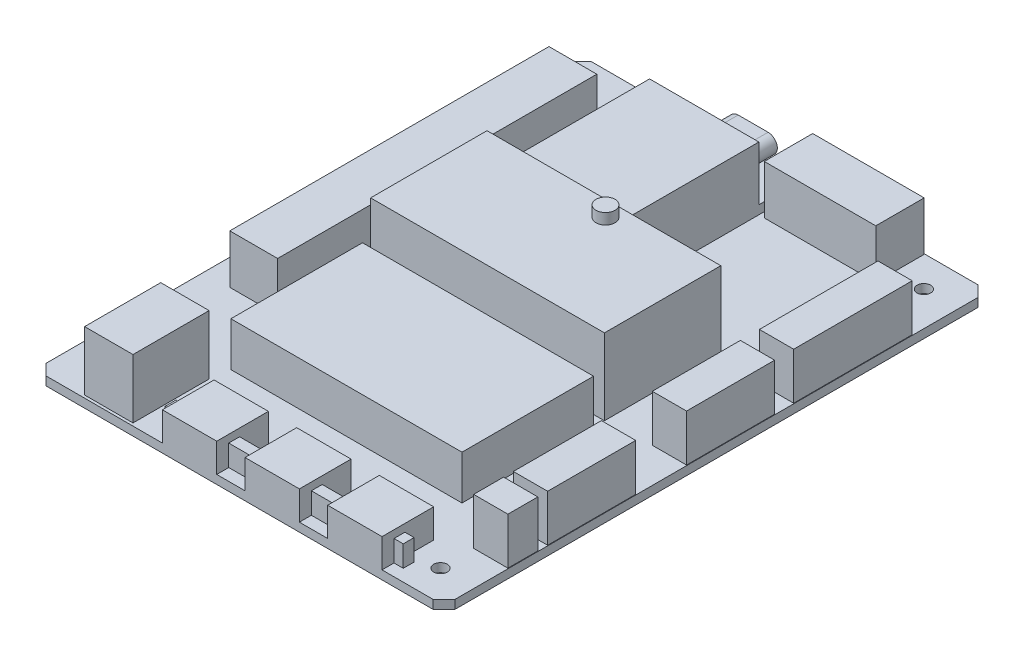
from build123d import *

# Parameters (mm, degrees)
SKETCH1_W            = 75.2
SKETCH1_H            = 100.2
BOSS_EXTRUDE1_DEPTH  = 1.6
CHAMFER1_SIZE        = 2
SKETCH2_R            = 1.25
CUT_EXTRUDE1_DEPTH   = 63.660434087
SKETCH3_W            = 8.8
SKETCH3_H            = 58.7
SKETCH3_W_2          = 20.5
SKETCH3_H_2          = 8.9
BOSS_EXTRUDE2_DEPTH  = 9
SKETCH3_3_W          = 20.1
SKETCH3_3_H          = 32
BOSS_EXTRUDE3_DEPTH  = 1.6
SKETCH3_4_W          = 6.3
SKETCH3_4_H          = 21.8
SKETCH3_4_H_2        = 16.2
SKETCH3_4_H_3        = 5.5
BOSS_EXTRUDE4_DEPTH  = 8.6
SKETCH3_5_W          = 10
SKETCH3_5_H          = 9.5
BOSS_EXTRUDE5_DEPTH  = 5.3
SKETCH3_6_W          = 8.9
SKETCH3_6_H          = 14
BOSS_EXTRUDE6_DEPTH  = 10.9
BOSS_EXTRUDE7_DEPTH  = 8
SKETCH5_W            = 43.8
SKETCH5_H            = 2
BOSS_EXTRUDE8_DEPTH  = 3.9
SKETCH7_W            = 42.5
SKETCH7_H            = 24.2
BOSS_EXTRUDE9_DEPTH  = 8.1
SKETCH7_3_W          = 43
SKETCH7_3_H          = 21.4
BOSS_EXTRUDE10_DEPTH = 14
SKETCH8_W            = 20.1
SKETCH8_H            = 24
BOSS_EXTRUDE11_DEPTH = 10
SKETCH9_R            = 1.75
BOSS_EXTRUDE12_DEPTH = 2


with BuildPart() as part:
    # Sketch1 → Boss-Extrude1 (new body)
    with BuildSketch(Plane(origin=(0, 0, 0), x_dir=(1, 0, 0), z_dir=(0, 1, 0))):
        Rectangle(SKETCH1_W, SKETCH1_H)
    extrude(amount=BOSS_EXTRUDE1_DEPTH)

    # Chamfer1
    chamfer1_edges = [part.edges().sort_by_distance(p)[0] for p in [
        (-37.6, 0.8, -50.1),
        (37.6, 0.8, -50.1),
        (-37.6, 0.8, 50.1),
        (37.6, 0.8, 50.1),
    ]]
    chamfer(chamfer1_edges, length=CHAMFER1_SIZE)

    # Sketch2 → Cut-Extrude1 (cut, through all)
    with BuildSketch(Plane(origin=(0, 1.6, 0), x_dir=(1, 0, 0), z_dir=(0, 1, 0))):
        with Locations((-32.2, 44.45)):
            Circle(SKETCH2_R)
        with Locations((-32.2, -44.45)):
            Circle(SKETCH2_R)
        with Locations((31.3, -44.45)):
            Circle(SKETCH2_R)
        with Locations((31.3, 44.45)):
            Circle(SKETCH2_R)
    extrude(amount=-CUT_EXTRUDE1_DEPTH, mode=Mode.SUBTRACT)

    # Sketch3 → Boss-Extrude2 (add)
    with BuildSketch(Plane(origin=(0, 1.6, 0), x_dir=(1, 0, 0), z_dir=(0, 1, 0))):
        with Locations((-28.4, 10.25)):
            Rectangle(SKETCH3_W, SKETCH3_H)
        with Locations((15.55, 45.55)):
            Rectangle(SKETCH3_W_2, SKETCH3_H_2)
    extrude(amount=BOSS_EXTRUDE2_DEPTH)

    # Sketch3_3 → Boss-Extrude3 (add)
    with BuildSketch(Plane(origin=(0, 1.6, 0), x_dir=(1, 0, 0), z_dir=(0, 1, 0))):
        with Locations((-5.75, 33.1)):
            Rectangle(SKETCH3_3_W, SKETCH3_3_H)
    extrude(amount=BOSS_EXTRUDE3_DEPTH)

    # Sketch3_4 → Boss-Extrude4 (add)
    with BuildSketch(Plane(origin=(0, 1.6, 0), x_dir=(1, 0, 0), z_dir=(0, 1, 0))):
        with Locations((34.35, 25.2)):
            Rectangle(SKETCH3_4_W, SKETCH3_4_H)
        with Locations((34.35, 2.7)):
            Rectangle(SKETCH3_4_W, SKETCH3_4_H_2)
        with Locations((34.35, -22.85)):
            Rectangle(SKETCH3_4_W, SKETCH3_4_H_2)
        with Locations((34.35, -35.5)):
            Rectangle(SKETCH3_4_W, SKETCH3_4_H_3)
    extrude(amount=BOSS_EXTRUDE4_DEPTH)

    # Sketch3_5 → Boss-Extrude5 (add)
    with BuildSketch(Plane(origin=(0, 1.6, 0), x_dir=(1, 0, 0), z_dir=(0, 1, 0))):
        with Locations((21.2, -45.35)):
            Rectangle(SKETCH3_5_W, SKETCH3_5_H)
        with Locations((6, -45.35)):
            Rectangle(SKETCH3_5_W, SKETCH3_5_H)
        with Locations((-9.2, -45.35)):
            Rectangle(SKETCH3_5_W, SKETCH3_5_H)
    extrude(amount=BOSS_EXTRUDE5_DEPTH)

    # Sketch3_6 → Boss-Extrude6 (add)
    with BuildSketch(Plane(origin=(0, 1.6, 0), x_dir=(1, 0, 0), z_dir=(0, 1, 0))):
        with Locations((-24.55, -42.6)):
            Rectangle(SKETCH3_6_W, SKETCH3_6_H)
    extrude(amount=BOSS_EXTRUDE6_DEPTH)

    # Sketch4 → Boss-Extrude7 (add)
    with BuildSketch(Plane(origin=(0, 0, -50.1), x_dir=(-1, 0, 0), z_dir=(0, 0, -1))):
        with BuildLine():
            Line((8.5, 3.2), (3, 3.2))
            ThreePointArc((3, 3.2), (1.3, 4.9), (3, 6.6))
            Line((3, 6.6), (8.5, 6.6))
            ThreePointArc((8.5, 6.6), (10.2, 4.9), (8.5, 3.2))
        make_face()
    extrude(amount=-BOSS_EXTRUDE7_DEPTH)

    # Sketch5 → Boss-Extrude8 (add)
    with BuildSketch(Plane(origin=(0, 1.6, 0), x_dir=(1, 0, 0), z_dir=(0, 1, 0))):
        with Locations((6, -46.9)):
            Rectangle(SKETCH5_W, SKETCH5_H)
    extrude(amount=BOSS_EXTRUDE8_DEPTH)

    # Sketch7 → Boss-Extrude9 (add)
    with BuildSketch(Plane(origin=(0, 1.6, 0), x_dir=(1, 0, 0), z_dir=(0, 1, 0))):
        with Locations((1.65, -20)):
            Rectangle(SKETCH7_W, SKETCH7_H)
    extrude(amount=BOSS_EXTRUDE9_DEPTH)

    # Sketch7_3 → Boss-Extrude10 (add)
    with BuildSketch(Plane(origin=(0, 1.6, 0), x_dir=(1, 0, 0), z_dir=(0, 1, 0))):
        with Locations((1.4, 4.8)):
            Rectangle(SKETCH7_3_W, SKETCH7_3_H)
    extrude(amount=BOSS_EXTRUDE10_DEPTH)

    # Sketch8 → Boss-Extrude11 (add)
    with BuildSketch(Plane(origin=(0, 3.2, 0), x_dir=(1, 0, 0), z_dir=(0, 1, 0))):
        with Locations((-5.75, 29.1)):
            Rectangle(SKETCH8_W, SKETCH8_H)
    extrude(amount=BOSS_EXTRUDE11_DEPTH)

    # Sketch9 → Boss-Extrude12 (add)
    with BuildSketch(Plane(origin=(0, 15.6, 0), x_dir=(1, 0, 0), z_dir=(0, 1, 0))):
        with Locations((4.6, 12.6)):
            Circle(SKETCH9_R)
    extrude(amount=BOSS_EXTRUDE12_DEPTH)


solid = part.part
